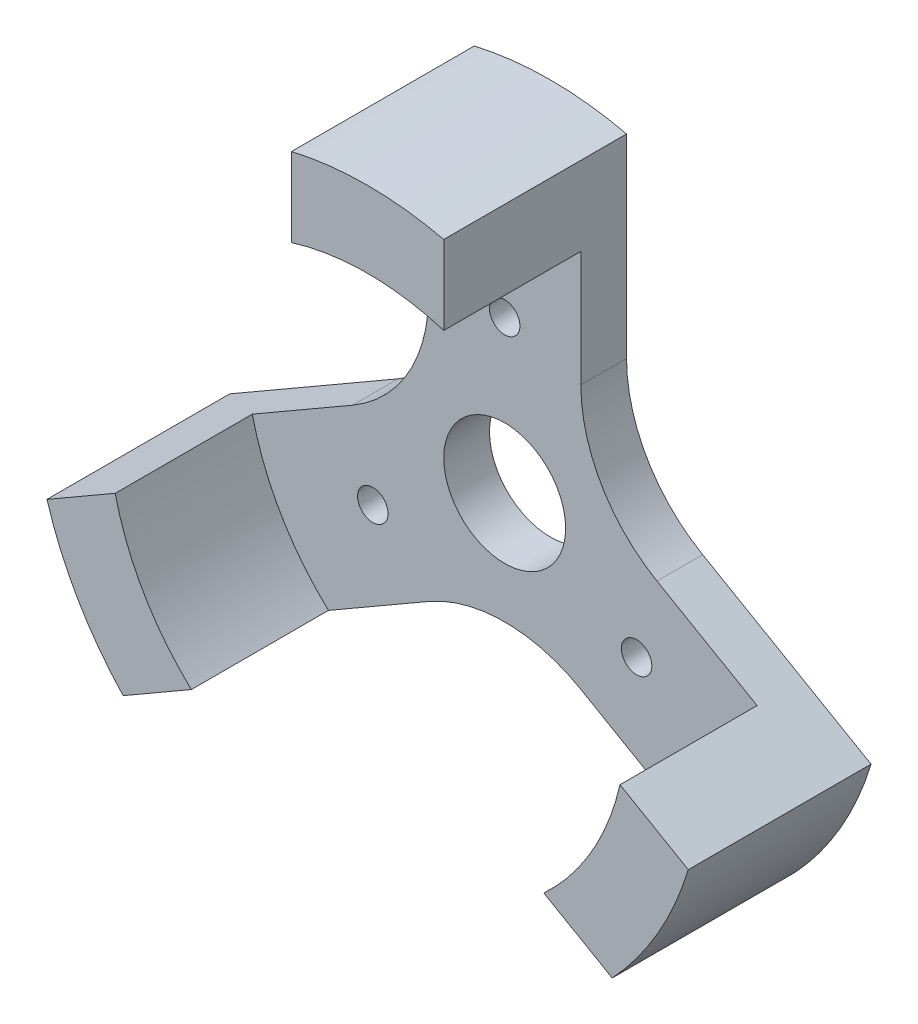
from build123d import *

# Parameters (mm, degrees)
SKETCH_1_R          = 22
SKETCH_1_R_2        = 17
EXTRUDE_1_DEPTH     = 9
SKETCH_2_R          = 22
EXTRUDE_2_DEPTH     = 3
SKETCH_3_R          = 1
CUT_EXTRUDE_1_DEPTH = 3
CUT_EXTRUDE_2_DEPTH = 25
SKETCH_5_R          = 4
CUT_EXTRUDE_3_DEPTH = 10
FILLET_1_R          = 10
FILLET_2_R          = 10


with BuildPart() as part:
    # 草图1 → 凸台-拉伸1 (new body)
    with BuildSketch(Plane.XY):
        Circle(SKETCH_1_R)
        Circle(SKETCH_1_R_2, mode=Mode.SUBTRACT)
    extrude(amount=EXTRUDE_1_DEPTH)

    # 草图2 → 凸台-拉伸2 (add)
    with BuildSketch(Plane(origin=(0, 0, 0), x_dir=(-1, 0, 0), z_dir=(0, 0, -1))):
        Circle(SKETCH_2_R)
    extrude(amount=EXTRUDE_2_DEPTH)

    # 草图3 → 切除-拉伸1 (cut)
    with BuildSketch(Plane(origin=(0, 0, -3), x_dir=(-1, 0, 0), z_dir=(0, 0, -1))):
        with Locations((0, 10)):
            Circle(SKETCH_3_R)
        with Locations((8.660254038, -5)):
            Circle(SKETCH_3_R)
        with Locations((-8.660254038, -5)):
            Circle(SKETCH_3_R)
    extrude(amount=-CUT_EXTRUDE_1_DEPTH, mode=Mode.SUBTRACT)

    # 草图4 → 切除-拉伸2 (cut)
    with BuildSketch(Plane(origin=(0, 0, -3), x_dir=(-1, 0, 0), z_dir=(0, 0, -1))):
        Polygon((24.787699458, -8.537682263), (5, 2.886751346), (5, 15), (5, 31.006622637), (28.596284234, 19.54376122), align=None)
        Polygon((-6.160254038, -9.330127019), (0, -5.773502692), (19.787699458, -17.197936301), (-4.03507969, -32.43608202), (-23.902747272, -19.573760264), align=None)
        Polygon((-5, 10), (-5, 2.886751346), (-28.902747272, -10.913506226), (-27.638085306, 27.170625695), (-5, 31.006622637), align=None)
    extrude(amount=-CUT_EXTRUDE_2_DEPTH, mode=Mode.SUBTRACT)

    # 草图5 → 切除-拉伸3 (cut)
    with BuildSketch(Plane(origin=(0, 0, -3), x_dir=(-1, 0, 0), z_dir=(0, 0, -1))):
        Circle(SKETCH_5_R)
    extrude(amount=-CUT_EXTRUDE_3_DEPTH, mode=Mode.SUBTRACT)

    # 圆角1
    fillet_1_edges = [part.edges().sort_by_distance(p)[0] for p in [
        (-5, 2.886751346, -1.5),
    ]]
    fillet(fillet_1_edges, radius=FILLET_1_R)

    # 圆角2
    fillet_2_edges = [part.edges().sort_by_distance(p)[0] for p in [
        (5, 2.886751346, -1.5),
        (0, -5.773502692, -1.5),
    ]]
    fillet(fillet_2_edges, radius=FILLET_2_R)


solid = part.part
